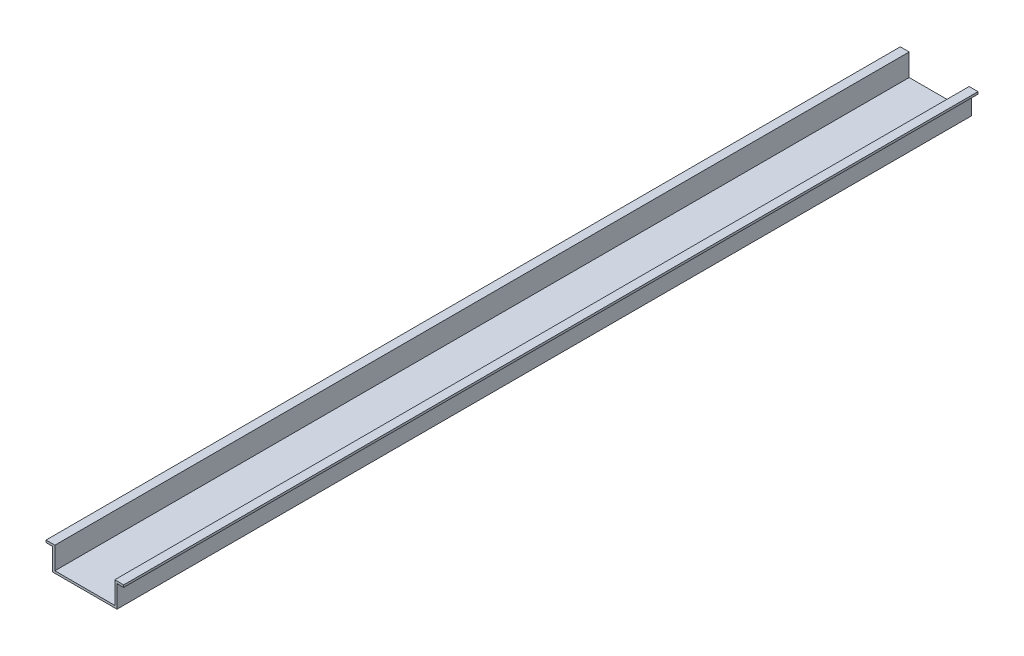
from build123d import *

# Parameters (mm, degrees)
BOSS_EXTRUDE1_DEPTH = 385


with BuildPart() as part:
    # Sketch1 → Boss-Extrude1 (new body)
    with BuildSketch(Plane.XY):
        Polygon((-17.5, 10), (-13.5, 10), (-13.5, 0), (13.5, 0), (13.5, 10), (17.5, 10), (17.5, 9), (14.5, 9), (14.5, -1), (-14.5, -1), (-14.5, 9), (-17.5, 9), align=None)
    extrude(amount=BOSS_EXTRUDE1_DEPTH)


solid = part.part
